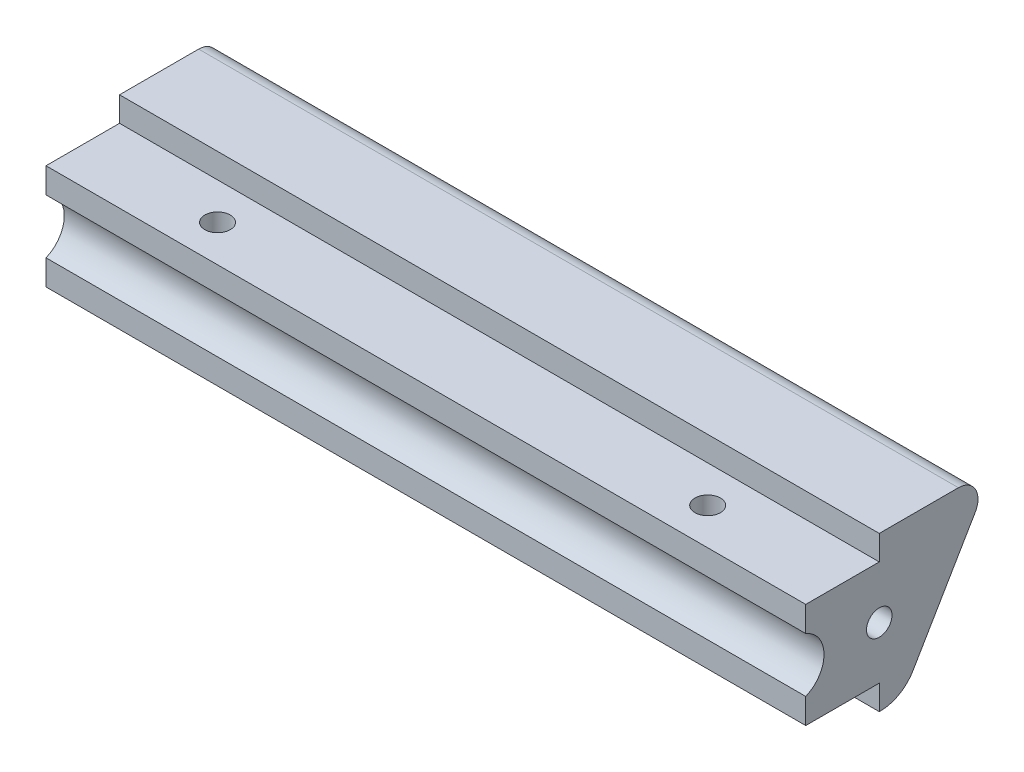
from build123d import *

# Parameters (mm, degrees)
BOSS_EXTRUDE1_DEPTH = 98.425
CUT_EXTRUDE2_DEPTH  = 98.425
SKETCH5_R           = 1.651
CUT_EXTRUDE3_DEPTH  = 13.5992
FILLET1_R           = 2.54
SKETCH6_R           = 1.651
CUT_EXTRUDE4_DEPTH  = 98.425


with BuildPart() as part:
    # Sketch1 → Boss-Extrude1 (new body)
    with BuildSketch(Plane(origin=(0, 0, 0), x_dir=(0, 0, -1), z_dir=(1, 0, 0))):
        with BuildLine():
            Line((0, 16.7996), (0, 3.2004))
            Line((0, 3.2004), (9.525, 3.2004))
            Line((9.525, 3.2004), (9.525, 0))
            Line((9.525, 0), (9.672001208, 0))
            ThreePointArc((9.672001208, 0), (12.1043061, 0.647018058), (13.89365381, 2.417039025))
            Line((13.89365381, 2.417039025), (24.215623453, 20))
            Line((24.215623453, 20), (9.525, 20))
            Line((9.525, 20), (9.525, 16.7996))
            Line((9.525, 16.7996), (0, 16.7996))
        make_face()
    extrude(amount=BOSS_EXTRUDE1_DEPTH)

    # Sketch4 → Cut-Extrude2 (cut)
    with BuildSketch(Plane.ZY):
        with BuildLine():
            Line((0, 13.526281186), (0, 6.473718814))
            ThreePointArc((0, 6.473718814), (-2.36728, 10), (0, 13.526281186))
        make_face()
    extrude(amount=-CUT_EXTRUDE2_DEPTH, mode=Mode.SUBTRACT)

    # Sketch5 → Cut-Extrude3 (cut)
    with BuildSketch(Plane(origin=(0, 16.7996, 0), x_dir=(1, 0, 0), z_dir=(0, 1, 0))):
        with Locations((17.4625, 4.7625)):
            Circle(SKETCH5_R)
        with Locations((80.9625, 4.7625)):
            Circle(SKETCH5_R)
    extrude(amount=-CUT_EXTRUDE3_DEPTH, mode=Mode.SUBTRACT)

    # Fillet1
    fillet1_edges = [part.edges().sort_by_distance(p)[0] for p in [
        (49.2125, 20, -24.215623453),
    ]]
    fillet(fillet1_edges, radius=FILLET1_R)

    # Sketch6 → Cut-Extrude4 (cut)
    with BuildSketch(Plane(origin=(98.425, 0, 0), x_dir=(0, 0, -1), z_dir=(1, 0, 0))):
        with Locations((9.525, 10)):
            Circle(SKETCH6_R)
    extrude(amount=-CUT_EXTRUDE4_DEPTH, mode=Mode.SUBTRACT)


solid = part.part
